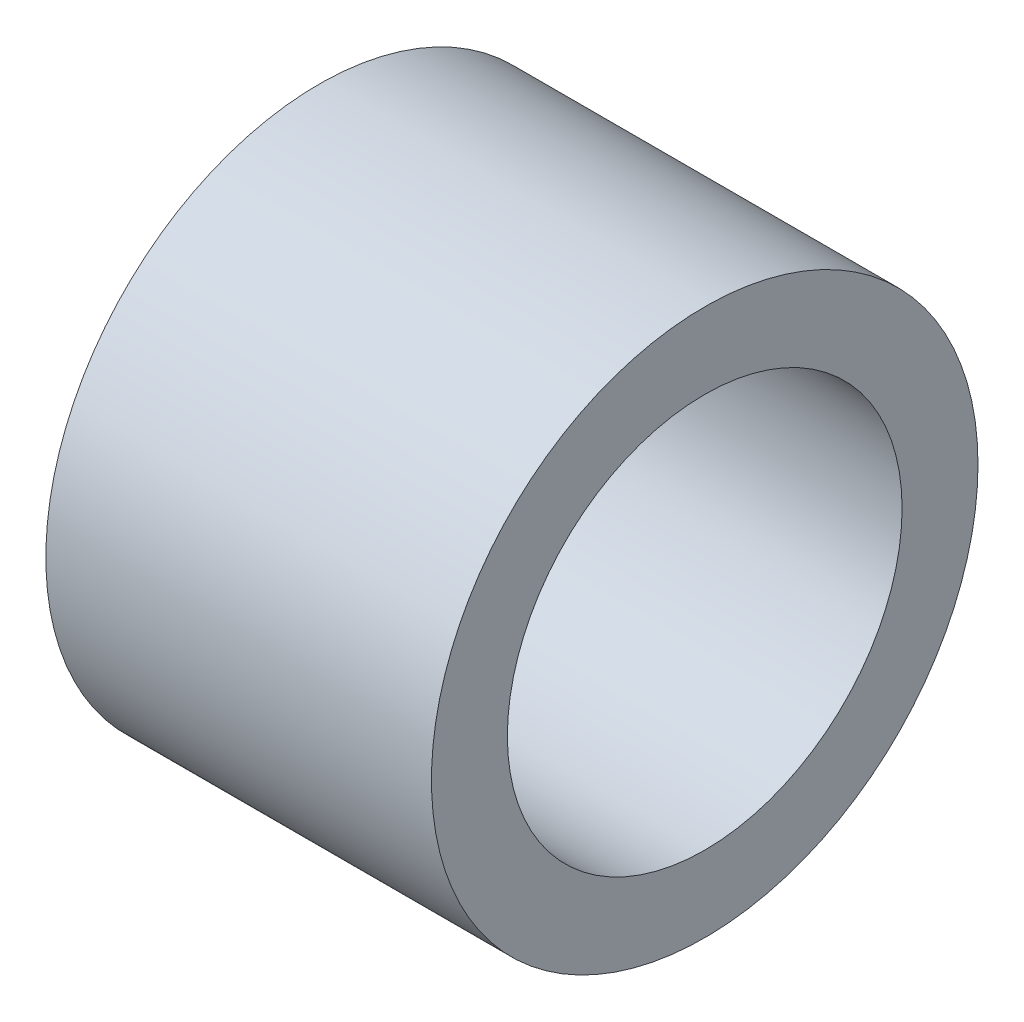
from build123d import *

# Parameters (mm, degrees)
SKETCH1_R           = 9
SKETCH1_R_2         = 6.5
BOSS_EXTRUDE1_DEPTH = 12.7


with BuildPart() as part:
    # Sketch1 → Boss-Extrude1 (new body)
    with BuildSketch(Plane(origin=(0, 0, 0), x_dir=(0, 0, -1), z_dir=(1, 0, 0))):
        Circle(SKETCH1_R)
        Circle(SKETCH1_R_2, mode=Mode.SUBTRACT)
    extrude(amount=BOSS_EXTRUDE1_DEPTH)


solid = part.part
